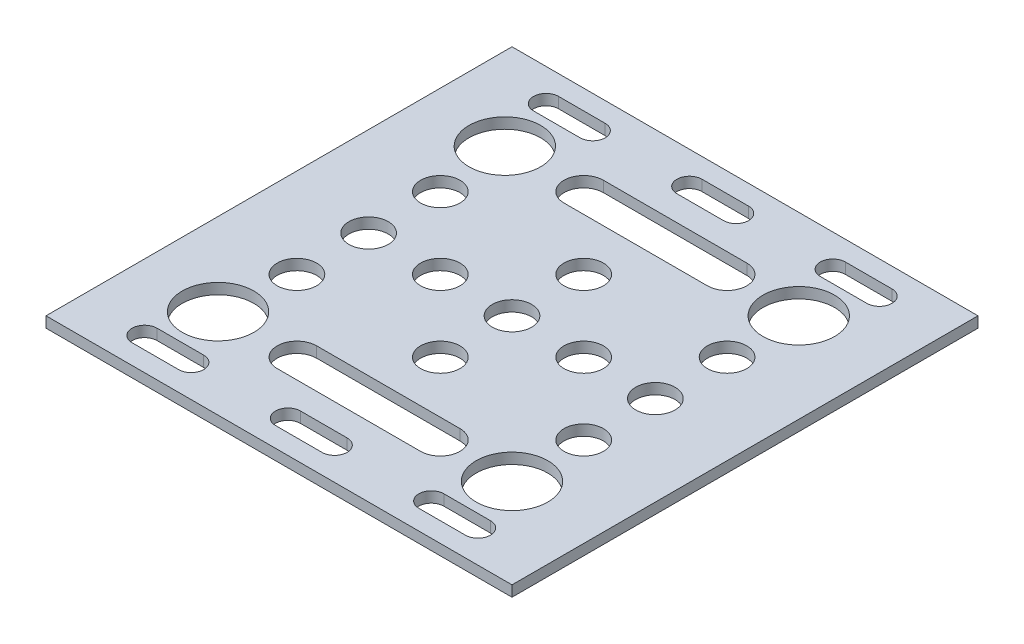
from build123d import *

# Parameters (mm, degrees)
SKETCH1_W           = 65
SKETCH1_H           = 65
SKETCH1_R           = 2.75
SKETCH1_R_2         = 5
BOSS_EXTRUDE1_DEPTH = 1.5


with BuildPart() as part:
    # Sketch1 → Boss-Extrude1 (new body)
    with BuildSketch(Plane(origin=(0, 0, 0), x_dir=(1, 0, 0), z_dir=(0, 1, 0))):
        with Locations((32.5, 32.5)):
            Rectangle(SKETCH1_W, SKETCH1_H)
        with Locations((32.5, 32.5)):
            Circle(SKETCH1_R, mode=Mode.SUBTRACT)
        with Locations((22.5, 32.5)):
            Circle(SKETCH1_R, mode=Mode.SUBTRACT)
        with Locations((12.5, 32.5)):
            Circle(SKETCH1_R, mode=Mode.SUBTRACT)
        with Locations((32.5, 42.5)):
            Circle(SKETCH1_R, mode=Mode.SUBTRACT)
        with Locations((12.5, 42.5)):
            Circle(SKETCH1_R, mode=Mode.SUBTRACT)
        with Locations((11.5, 52.5)):
            Circle(SKETCH1_R_2, mode=Mode.SUBTRACT)
        with Locations((42.5, 32.5)):
            Circle(SKETCH1_R, mode=Mode.SUBTRACT)
        with Locations((52.5, 32.5)):
            Circle(SKETCH1_R, mode=Mode.SUBTRACT)
        with Locations((52.5, 42.5)):
            Circle(SKETCH1_R, mode=Mode.SUBTRACT)
        with Locations((52.5, 22.5)):
            Circle(SKETCH1_R, mode=Mode.SUBTRACT)
        with Locations((32.5, 22.5)):
            Circle(SKETCH1_R, mode=Mode.SUBTRACT)
        with Locations((12.5, 22.5)):
            Circle(SKETCH1_R, mode=Mode.SUBTRACT)
        with Locations((11.5, 12.5)):
            Circle(SKETCH1_R_2, mode=Mode.SUBTRACT)
        with Locations((52.5, 52.5)):
            Circle(SKETCH1_R_2, mode=Mode.SUBTRACT)
        with Locations((52.5, 12.5)):
            Circle(SKETCH1_R_2, mode=Mode.SUBTRACT)
        with BuildLine():
            Line((22.5, 55.25), (42.5, 55.25))
            ThreePointArc((42.5, 55.25), (45.25, 52.5), (42.5, 49.75))
            Line((42.5, 49.75), (22.5, 49.75))
            ThreePointArc((22.5, 49.75), (19.75, 52.5), (22.5, 55.25))
        make_face(mode=Mode.SUBTRACT)
        with BuildLine():
            Line((29.25, 62.25), (35.75, 62.25))
            ThreePointArc((35.75, 62.25), (37.5, 60.5), (35.75, 58.75))
            Line((35.75, 58.75), (29.25, 58.75))
            ThreePointArc((29.25, 58.75), (27.5, 60.5), (29.25, 62.25))
        make_face(mode=Mode.SUBTRACT)
        with BuildLine():
            Line((9.25, 62.25), (15.75, 62.25))
            ThreePointArc((15.75, 62.25), (17.5, 60.5), (15.75, 58.75))
            Line((15.75, 58.75), (9.25, 58.75))
            ThreePointArc((9.25, 58.75), (7.5, 60.5), (9.25, 62.25))
        make_face(mode=Mode.SUBTRACT)
        with BuildLine():
            Line((55.75, 62.25), (49.25, 62.25))
            ThreePointArc((49.25, 62.25), (47.5, 60.5), (49.25, 58.75))
            Line((49.25, 58.75), (55.75, 58.75))
            ThreePointArc((55.75, 58.75), (57.5, 60.5), (55.75, 62.25))
        make_face(mode=Mode.SUBTRACT)
        with BuildLine():
            Line((22.5, 9.75), (42.5, 9.75))
            ThreePointArc((42.5, 9.75), (45.25, 12.5), (42.5, 15.25))
            Line((42.5, 15.25), (22.5, 15.25))
            ThreePointArc((22.5, 15.25), (19.75, 12.5), (22.5, 9.75))
        make_face(mode=Mode.SUBTRACT)
        with BuildLine():
            Line((55.75, 2.75), (49.25, 2.75))
            ThreePointArc((49.25, 2.75), (47.5, 4.5), (49.25, 6.25))
            Line((49.25, 6.25), (55.75, 6.25))
            ThreePointArc((55.75, 6.25), (57.5, 4.5), (55.75, 2.75))
        make_face(mode=Mode.SUBTRACT)
        with BuildLine():
            Line((9.25, 2.75), (15.75, 2.75))
            ThreePointArc((15.75, 2.75), (17.5, 4.5), (15.75, 6.25))
            Line((15.75, 6.25), (9.25, 6.25))
            ThreePointArc((9.25, 6.25), (7.5, 4.5), (9.25, 2.75))
        make_face(mode=Mode.SUBTRACT)
        with BuildLine():
            Line((29.25, 2.75), (35.75, 2.75))
            ThreePointArc((35.75, 2.75), (37.5, 4.5), (35.75, 6.25))
            Line((35.75, 6.25), (29.25, 6.25))
            ThreePointArc((29.25, 6.25), (27.5, 4.5), (29.25, 2.75))
        make_face(mode=Mode.SUBTRACT)
    extrude(amount=BOSS_EXTRUDE1_DEPTH)


solid = part.part
